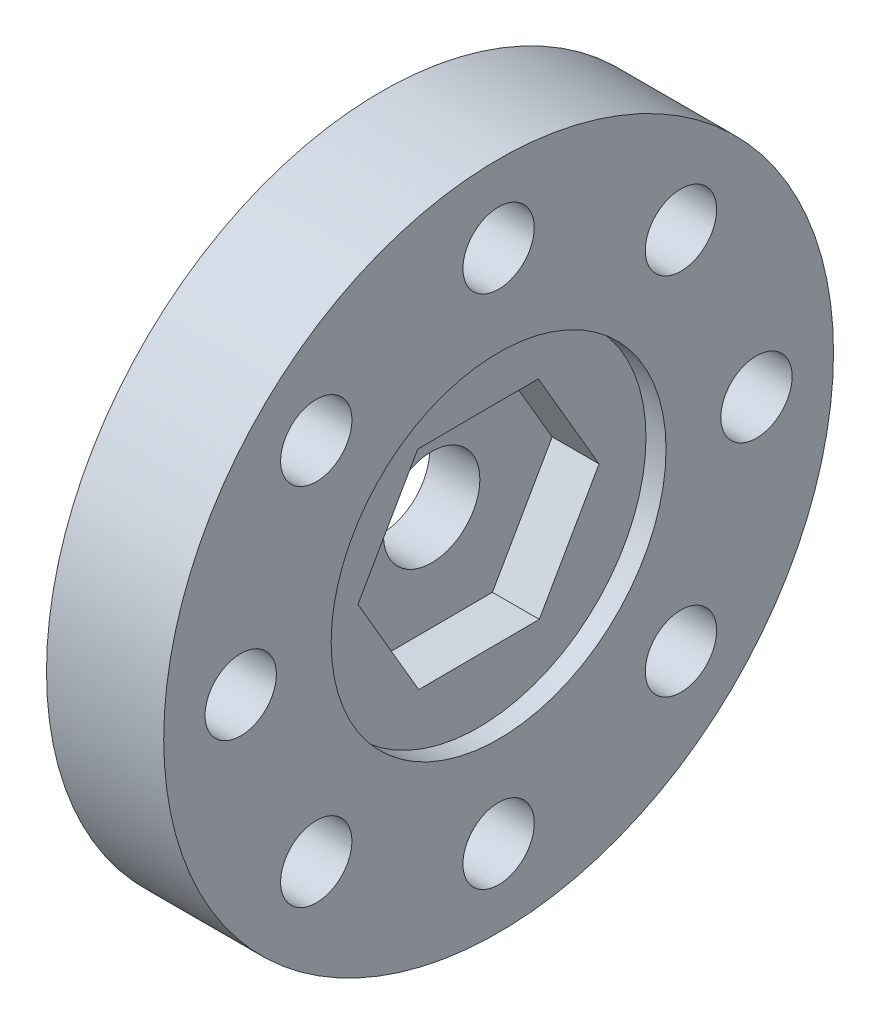
from build123d import *

# Parameters (mm, degrees)
SKETCH1_R           = 12.7
SKETCH1_R_2         = 1.35255
BOSS_EXTRUDE1_DEPTH = 4.445
SKETCH2_R           = 6.35
CUT_EXTRUDE1_DEPTH  = 0.762
CUT_EXTRUDE4_DEPTH  = 1.778
SKETCH6_R           = 1.8288
CUT_EXTRUDE5_DEPTH  = 2.905


with BuildPart() as part:
    # Sketch1 → Boss-Extrude1 (new body)
    with BuildSketch(Plane(origin=(0, 0, 0), x_dir=(0, 0, -1), z_dir=(1, 0, 0))):
        Circle(SKETCH1_R)
        with Locations((0, 9.779)):
            Circle(SKETCH1_R_2, mode=Mode.SUBTRACT)
        with Locations((6.914797213, 6.914797213)):
            Circle(SKETCH1_R_2, mode=Mode.SUBTRACT)
        with Locations((9.779, 0)):
            Circle(SKETCH1_R_2, mode=Mode.SUBTRACT)
        with Locations((6.914797213, -6.914797213)):
            Circle(SKETCH1_R_2, mode=Mode.SUBTRACT)
        with Locations((0, -9.779)):
            Circle(SKETCH1_R_2, mode=Mode.SUBTRACT)
        with Locations((-6.914797213, -6.914797213)):
            Circle(SKETCH1_R_2, mode=Mode.SUBTRACT)
        with Locations((-9.779, 0)):
            Circle(SKETCH1_R_2, mode=Mode.SUBTRACT)
        with Locations((-6.914797213, 6.914797213)):
            Circle(SKETCH1_R_2, mode=Mode.SUBTRACT)
    extrude(amount=BOSS_EXTRUDE1_DEPTH)

    # Sketch2 → Cut-Extrude1 (cut)
    with BuildSketch(Plane(origin=(4.445, 0, 0), x_dir=(0, 0, -1), z_dir=(1, 0, 0))):
        Circle(SKETCH2_R)
    extrude(amount=-CUT_EXTRUDE1_DEPTH, mode=Mode.SUBTRACT)

    # Sketch5 → Cut-Extrude4 (cut)
    with BuildSketch(Plane(origin=(3.683, 0, 0), x_dir=(0, 0, -1), z_dir=(1, 0, 0))):
        Polygon((-2.305627782, 3.948070989), (-4.571943663, -0.022696736), (-2.266315881, -3.970767725), (2.305627782, -3.948070989), (4.571943663, 0.022696736), (2.266315881, 3.970767725), align=None)
    extrude(amount=-CUT_EXTRUDE4_DEPTH, mode=Mode.SUBTRACT)

    # Sketch6 → Cut-Extrude5 (cut, through all)
    with BuildSketch(Plane(origin=(1.905, 0, 0), x_dir=(0, 0, -1), z_dir=(1, 0, 0))):
        Circle(SKETCH6_R)
    extrude(amount=-CUT_EXTRUDE5_DEPTH, mode=Mode.SUBTRACT)


solid = part.part
